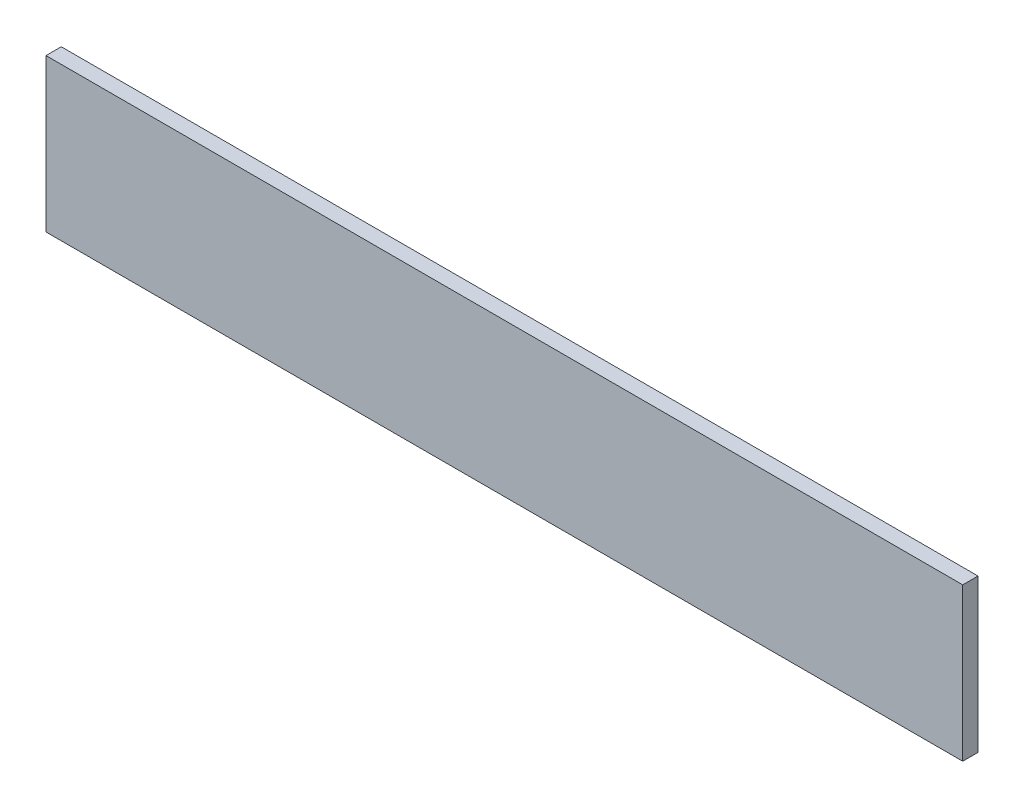
from build123d import *

# Parameters (mm, degrees)
SKETCH_1_W      = 120
SKETCH_1_H      = 20
EXTRUDE_1_DEPTH = 2


with BuildPart() as part:
    # Sketch 1 → Бобышка-Вытянуть1 (new body)
    with BuildSketch(Plane.XY):
        with Locations((60, -10)):
            Rectangle(SKETCH_1_W, SKETCH_1_H)
    extrude(amount=EXTRUDE_1_DEPTH)


solid = part.part
